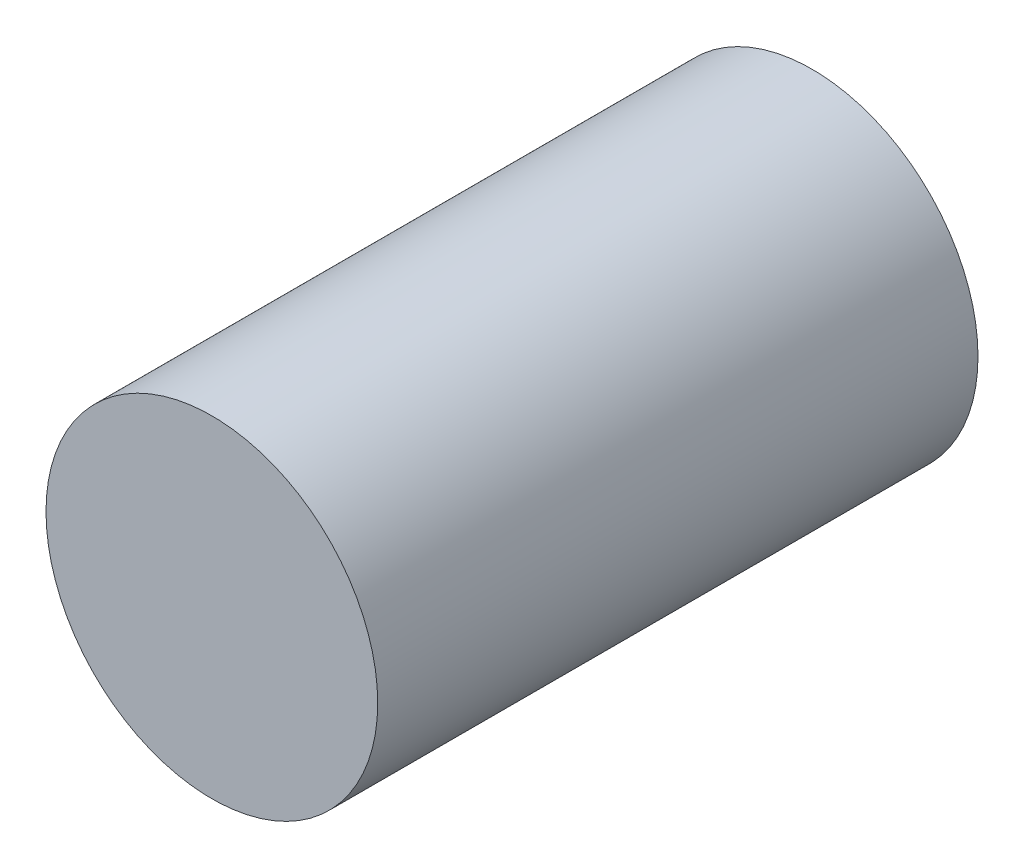
from build123d import *

# Parameters (mm, degrees)
SKETCH1_R           = 2.625
BOSS_EXTRUDE1_DEPTH = 9.5


with BuildPart() as part:
    # Sketch1 → Boss-Extrude1 (new body)
    with BuildSketch(Plane.XY):
        Circle(SKETCH1_R)
    extrude(amount=BOSS_EXTRUDE1_DEPTH)


solid = part.part
